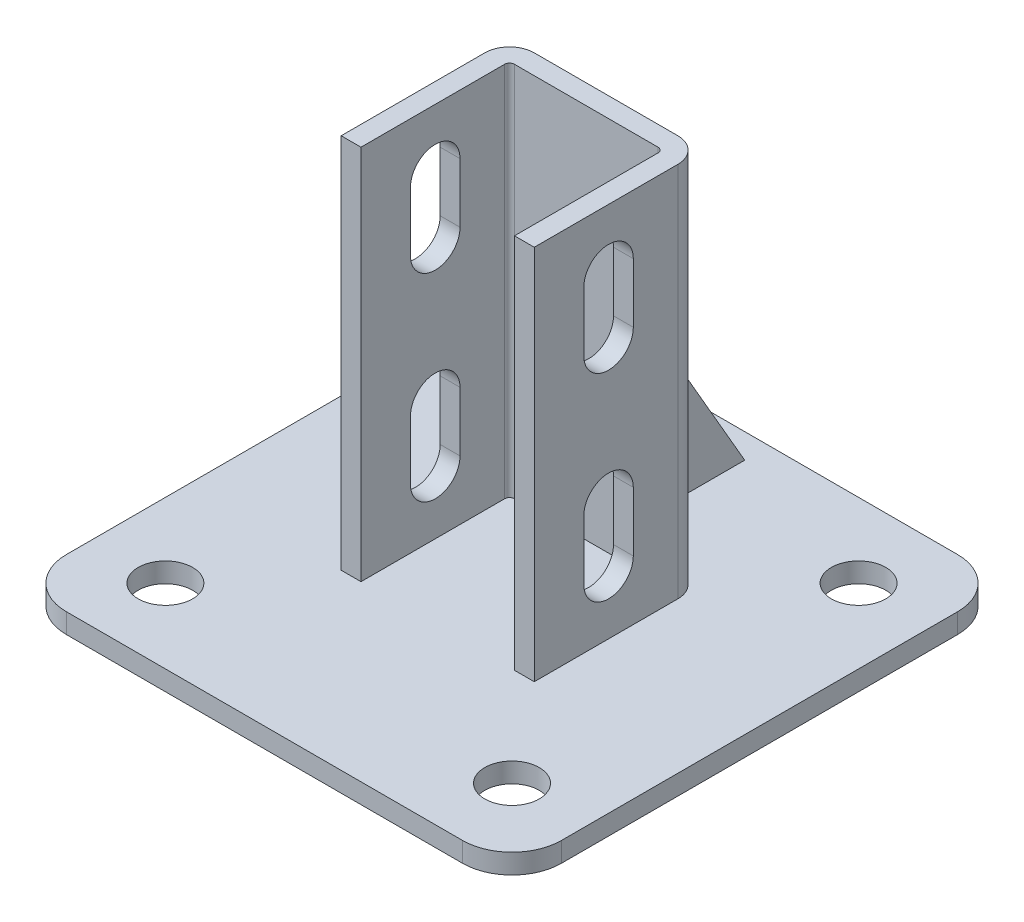
from build123d import *

# Parameters (mm, degrees)
SKETCH_2_W          = 100
SKETCH_2_H          = 100
EXTRUDE_1_DEPTH     = 4
EXTRUDE_1_2_DEPTH   = 76
EXTRUDE_2_DEPTH     = 2
CUT_EXTRUDE_1_DEPTH = 70.5
SKETCH_6_R          = 5.5
CUT_EXTRUDE_2_DEPTH = 5
FILLET_1_R          = 10


with BuildPart() as part:
    # Эскиз2 → Extrude 1 (new body)
    with BuildSketch(Plane(origin=(0, 0, 0), x_dir=(1, 0, 0), z_dir=(0, 1, 0))):
        Rectangle(SKETCH_2_W, SKETCH_2_H)
    extrude(amount=EXTRUDE_1_DEPTH)

    # Эскиз3 → Extrude 1 2 (add)
    with BuildSketch(Plane(origin=(0, 4, 0), x_dir=(1, 0, 0), z_dir=(0, 1, 0))):
        with BuildLine():
            Line((-15.5, -15), (-15.5, 14))
            ThreePointArc((-15.5, 14), (-15.207106781, 14.707106781), (-14.5, 15))
            Line((-14.5, 15), (14.5, 15))
            ThreePointArc((14.5, 15), (15.207106781, 14.707106781), (15.5, 14))
            Line((15.5, 14), (15.5, -15))
            Line((15.5, -15), (19.5, -15))
            Line((19.5, -15), (19.5, 14))
            ThreePointArc((19.5, 14), (18.035533906, 17.535533906), (14.5, 19))
            Line((14.5, 19), (-14.5, 19))
            ThreePointArc((-14.5, 19), (-18.035533906, 17.535533906), (-19.5, 14))
            Line((-19.5, 14), (-19.5, -15))
            Line((-19.5, -15), (-15.5, -15))
        make_face()
    extrude(amount=EXTRUDE_1_2_DEPTH)

    # Эскиз4 → Бобышка-Вытянуть2 (add, symmetric)
    with BuildSketch(Plane(origin=(0, 0, 0), x_dir=(0, 0, -1), z_dir=(1, 0, 0))):
        Polygon((19, 49.033320997), (45, 4), (19, 4), align=None)
    extrude(amount=EXTRUDE_2_DEPTH, both=True)

    # Эскиз5 → Вырез-Вытянуть1 (cut, through all)
    with BuildSketch(Plane(origin=(19.5, 0, 0), x_dir=(0, 0, -1), z_dir=(1, 0, 0))):
        with BuildLine():
            Line((5, 68), (5, 56))
            ThreePointArc((5, 56), (0, 51), (-5, 56))
            Line((-5, 56), (-5, 68))
            ThreePointArc((-5, 68), (0, 73), (5, 68))
        make_face()
        with BuildLine():
            Line((5, 28), (5, 16))
            ThreePointArc((5, 16), (0, 11), (-5, 16))
            Line((-5, 16), (-5, 28))
            ThreePointArc((-5, 28), (0, 33), (5, 28))
        make_face()
    extrude(amount=-CUT_EXTRUDE_1_DEPTH, mode=Mode.SUBTRACT)

    # Эскиз6 → Вырез-Вытянуть2 (cut, through all)
    with BuildSketch(Plane(origin=(0, 4, 0), x_dir=(1, 0, 0), z_dir=(0, 1, 0))):
        with Locations(Location((-35, 35, 0), (0, 0, 270))):  # turned: the seam where the file's is
            Circle(SKETCH_6_R)
        with Locations(Location((-35, -35, 0), (0, 0, 270))):  # turned: the seam where the file's is
            Circle(SKETCH_6_R)
        with Locations(Location((35, 35, 0), (0, 0, 270))):  # turned: the seam where the file's is
            Circle(SKETCH_6_R)
        with Locations(Location((35, -35, 0), (0, 0, 270))):  # turned: the seam where the file's is
            Circle(SKETCH_6_R)
    extrude(amount=-CUT_EXTRUDE_2_DEPTH, mode=Mode.SUBTRACT)

    # Скругление1
    fillet_1_edges = [part.edges().sort_by_distance(p)[0] for p in [
        (50, 2, 50),
        (-50, 2, 50),
        (-50, 2, -50),
        (50, 2, -50),
    ]]
    fillet(fillet_1_edges, radius=FILLET_1_R)


solid = part.part
